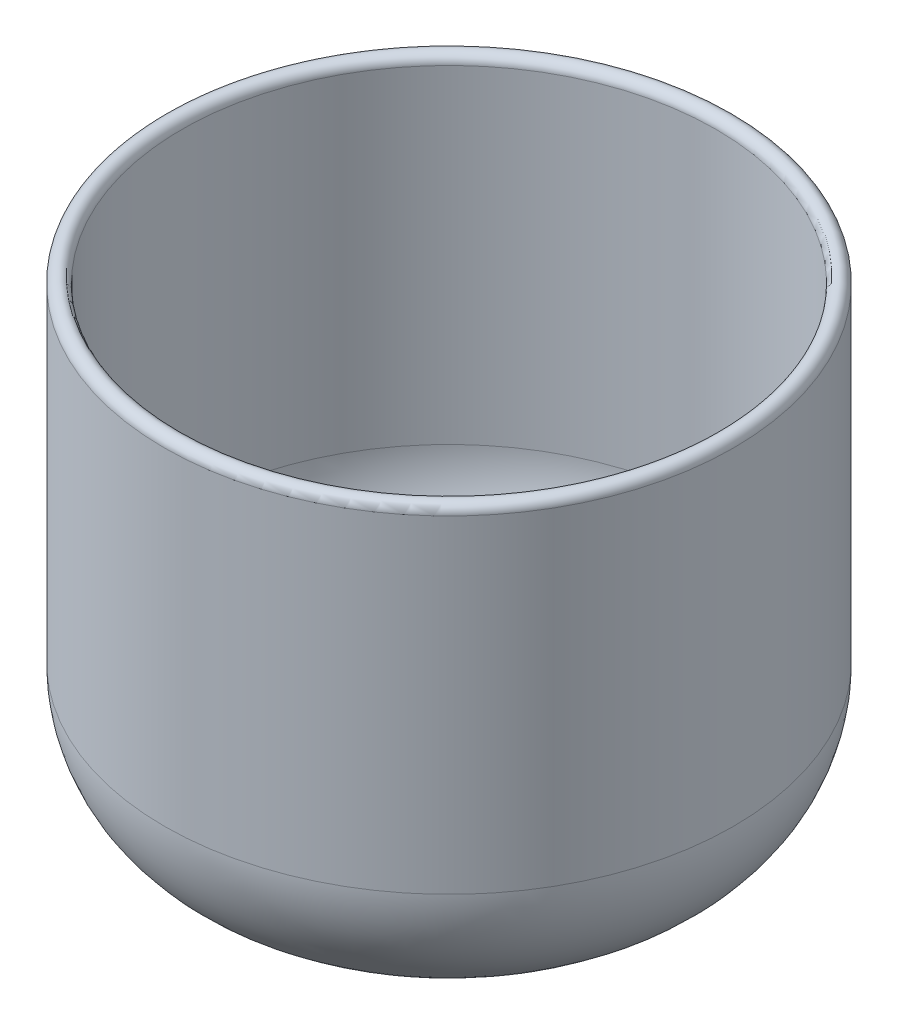
from build123d import *


with BuildPart() as part:
    # Sketch1 → Revolve1 (revolve)
    with BuildSketch(Plane.XY):
        with BuildLine():
            Line((0, 0), (12.7, 0))
            ThreePointArc((12.7, 0), (18.686592918, 0.271905112), (24.623888889, 1.085381429))
            ThreePointArc((24.623888889, 1.085381429), (36.566761948, 8.064677779), (41.275, 21.071417912))
            Line((41.275, 21.071417912), (41.275, 68.602618404))
            ThreePointArc((41.275, 68.602618404), (40.018407707, 69.89932214), (38.734934185, 68.629219589))
            Line((38.734934185, 68.629219589), (38.734934185, 21.023040538))
            ThreePointArc((38.734934185, 21.023040538), (34.599795979, 9.671946754), (24.165277778, 3.583635989))
            ThreePointArc((24.165277778, 3.583635989), (18.456339345, 2.801447223), (12.7, 2.54))
            Line((12.7, 2.54), (0, 2.54))
            Line((0, 2.54), (0, 0))
        make_face()
    revolve(axis=Axis((0, 0, 0), (0, 1, 0)))


solid = part.part
